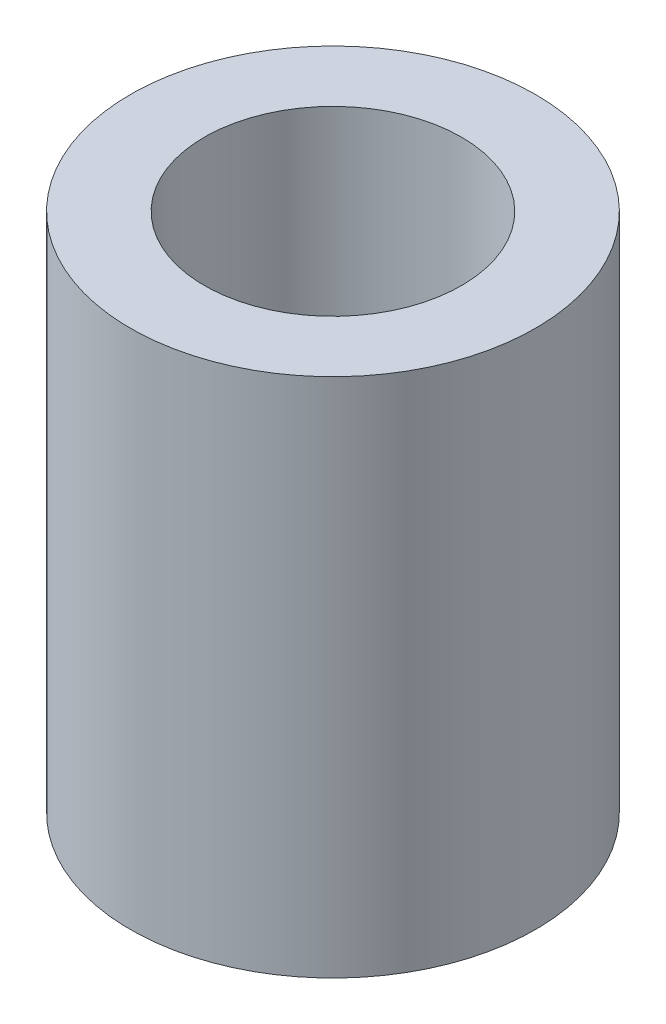
from build123d import *

# Parameters (mm, degrees)
SKETCH1_W = 1.15
SKETCH1_H = 8.1


with BuildPart() as part:
    # Sketch1 → Revolve1 (revolve)
    with BuildSketch(Plane.XY):
        with Locations((2.575, 4.05)):
            Rectangle(SKETCH1_W, SKETCH1_H)
    revolve(axis=Axis((0, 0, 0), (0, 1, 0)))


solid = part.part
